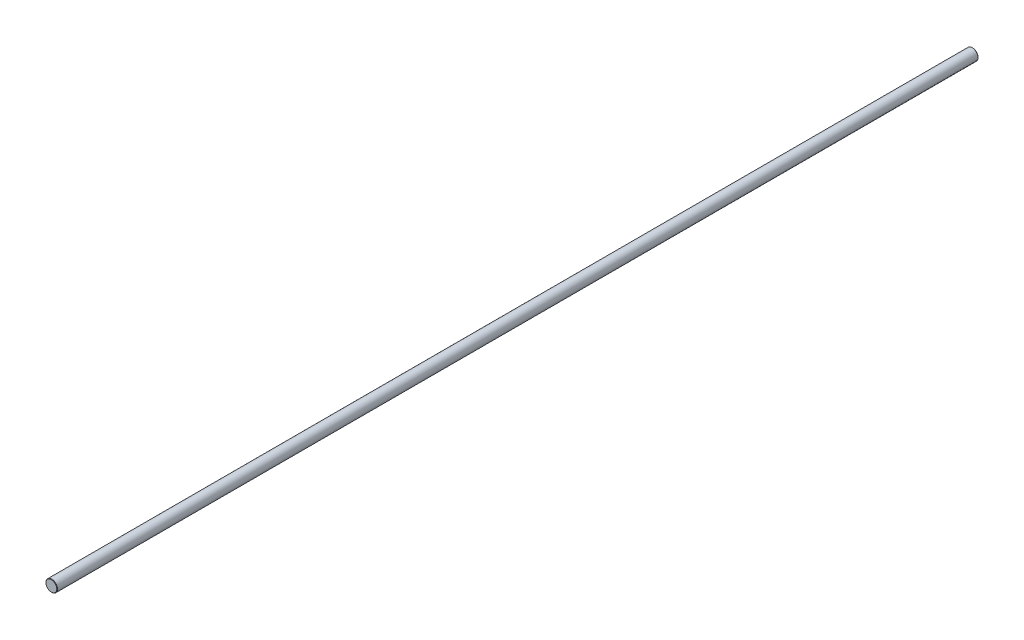
from build123d import *

# Parameters (mm, degrees)
SCHIZZO1_R                   = 4
ESTRUSIONE_ESTRUSIONE1_DEPTH = 640
SMUSSO1_SIZE                 = 0.25


with BuildPart() as part:
    # Schizzo1 → Estrusione-Estrusione1 (new body)
    with BuildSketch(Plane.XY):
        Circle(SCHIZZO1_R)
    extrude(amount=ESTRUSIONE_ESTRUSIONE1_DEPTH)

    # Smusso1
    smusso1_edges = [part.edges().sort_by_distance(p)[0] for p in [
        (-4, 0, 0),
        (-4, 0, 640),
    ]]
    chamfer(smusso1_edges, length=SMUSSO1_SIZE)


solid = part.part
